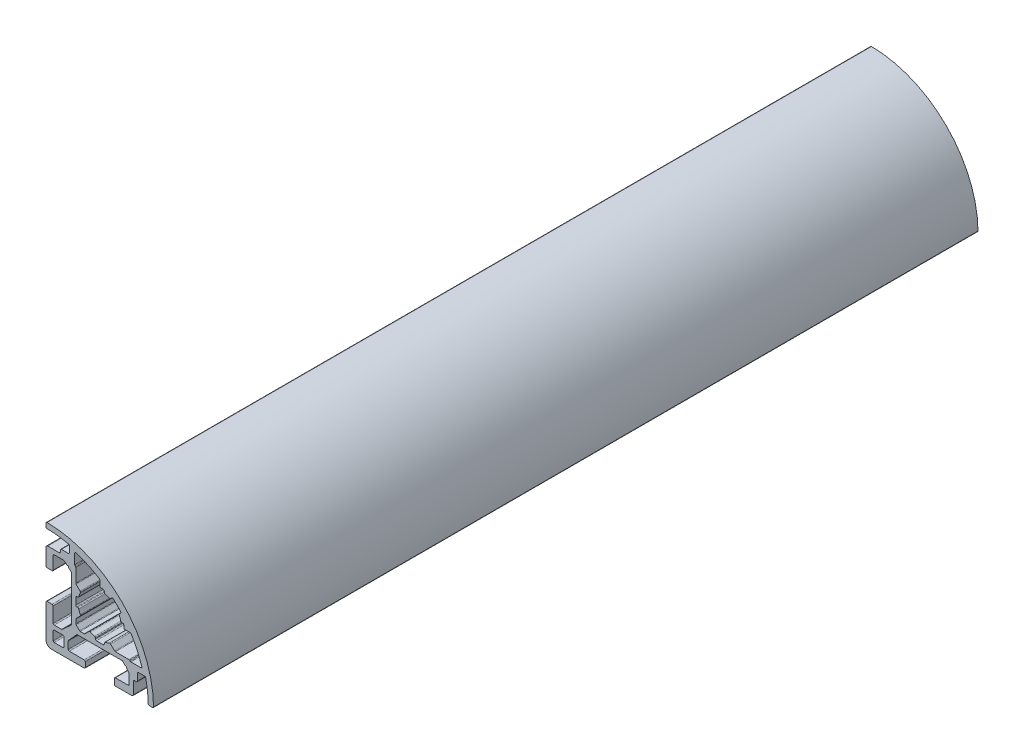
from build123d import *

# Parameters (mm, degrees)
RESSALTO_EXTRUS_O1_DEPTH = 230


with BuildPart() as part:
    # Esboço1 → Ressalto-extrusão1 (new body)
    with BuildSketch(Plane(origin=(0, 0, 0), x_dir=(-1, 0, 0), z_dir=(0, 0, -1))):
        with BuildLine():
            Line((7.988219541, 6.43198304), (8.704487641, 7.072027255))
            Line((8.704487641, 7.072027255), (8.728293149, 7.495764433))
            Line((8.728293149, 7.495764433), (9.151562381, 7.471985214))
            Line((9.151562381, 7.471985214), (9.867827891, 8.112011499))
            ThreePointArc((9.867827891, 8.112011499), (9.965155948, 8.177041744), (10.079961344, 8.199876023))
            Line((10.079961344, 8.199876023), (12.700062747, 8.19983357))
            ThreePointArc((12.700062747, 8.19983357), (12.912193499, 8.111962025), (13.000057886, 7.899828307))
            Line((13.000057886, 7.899828307), (12.999995614, 4.349871329))
            ThreePointArc((12.999995614, 4.349871329), (13.087860246, 4.137737366), (13.299991447, 4.049866067))
            Line((13.299991447, 4.049866067), (14.699990096, 4.049846624))
            ThreePointArc((14.699990096, 4.049846624), (14.912124824, 4.137713117), (14.999994262, 4.349846624))
            Line((14.999994262, 4.349846624), (14.999994262, 8.899908545))
            ThreePointArc((14.999994262, 8.899908545), (14.853547653, 9.253461936), (14.499994262, 9.399908545))
            Line((14.499994262, 9.399908545), (11.299984015, 9.399908545))
            ThreePointArc((11.299984015, 9.399908545), (11.087851981, 9.487776511), (10.999984015, 9.699908545))
            Line((10.999984015, 9.699908545), (10.999984015, 10.199939564))
            ThreePointArc((10.999984015, 10.199939564), (10.91211588, 10.412072007), (10.699983437, 10.499940142))
            Line((10.699983437, 10.499940142), (8.799996289, 10.499940142))
            ThreePointArc((8.799996289, 10.499940142), (8.587864255, 10.587808108), (8.499996289, 10.799940142))
            Line((8.499996289, 10.799940142), (8.499996289, 12.509984621))
            ThreePointArc((8.499996289, 12.509984621), (8.565702422, 12.697351597), (8.734038846, 12.802644177))
            ThreePointArc((8.734038846, 12.802644177), (11.700188414, 13.308311468), (14.703119279, 13.498440079))
            ThreePointArc((14.703119279, 13.498440079), (14.913228295, 13.587399521), (14.999994262, 13.798423803))
            Line((14.999994262, 13.798423803), (14.999994262, 14.698471418))
            ThreePointArc((14.999994262, 14.698471418), (14.911052198, 14.911672141), (14.696963943, 14.998456113))
            ThreePointArc((14.696963943, 14.998456113), (-6.213201777, 6.213195799), (-14.998473404, -14.696965168))
            ThreePointArc((-14.998473404, -14.696965168), (-14.91168949, -14.911053528), (-14.69848871, -14.99999565))
            Line((-14.69848871, -14.99999565), (-13.798441347, -14.99999565))
            ThreePointArc((-13.798441347, -14.99999565), (-13.587416943, -14.913229667), (-13.498457365, -14.70312058))
            ThreePointArc((-13.498457365, -14.70312058), (-13.308326814, -11.700187782), (-12.802657176, -8.734036533))
            ThreePointArc((-12.802657176, -8.734036533), (-12.69756035, -8.565856959), (-12.510499232, -8.499994604))
            Line((-12.510499232, -8.499994604), (-10.800466095, -8.49997976))
            ThreePointArc((-10.800466095, -8.49997976), (-10.588332377, -8.587846805), (-10.500463491, -8.79997976))
            Line((-10.500463491, -8.79997976), (-10.500463491, -10.699963204))
            ThreePointArc((-10.500463491, -10.699963204), (-10.412595525, -10.912095238), (-10.200463491, -10.999963204))
            Line((-10.200463491, -10.999963204), (-9.700412566, -10.999963204))
            ThreePointArc((-9.700412566, -10.999963204), (-9.488279549, -11.087832151), (-9.400412566, -11.299965981))
            Line((-9.400412566, -11.299965981), (-9.400442195, -14.49999102))
            ThreePointArc((-9.400442195, -14.49999102), (-9.253997222, -14.853547404), (-8.900442195, -14.99999565))
            Line((-8.900442195, -14.99999565), (-4.350452588, -14.99999565))
            ThreePointArc((-4.350452588, -14.99999565), (-4.138321045, -14.912128175), (-4.050452588, -14.699997039))
            Line((-4.050452588, -14.699997039), (-4.050446106, -13.299966156))
            ThreePointArc((-4.050446106, -13.299966156), (-4.138313076, -13.087833729), (-4.350444677, -12.999964767))
            Line((-4.350444677, -12.999964767), (-7.900453147, -12.999947852))
            ThreePointArc((-7.900453147, -12.999947852), (-8.112584739, -12.912078899), (-8.200451717, -12.699946488))
            Line((-8.200451717, -12.699946488), (-8.200439807, -10.079879081))
            ThreePointArc((-8.200439807, -10.079879081), (-8.177603146, -9.965074158), (-8.112570881, -9.867747451))
            Line((-8.112570881, -9.867747451), (-7.472516649, -9.151499458))
            Line((-7.472516649, -9.151499458), (-7.496307792, -8.728000464))
            Line((-7.496307792, -8.728000464), (-7.072695416, -8.704202951))
            Line((-7.072695416, -8.704202951), (-6.432641182, -7.987954957))
            ThreePointArc((-6.432641182, -7.987954957), (-6.335313867, -7.922923563), (-6.220508714, -7.900087947))
            Line((-6.220508714, -7.900087947), (6.219693639, -7.900145542))
            ThreePointArc((6.219693639, -7.900145542), (6.334497914, -7.922981945), (6.431824273, -7.988013496))
            Line((6.431824273, -7.988013496), (8.711723784, -10.467916072))
            ThreePointArc((8.711723784, -10.467916072), (8.776761946, -10.565245573), (8.799600801, -10.680055769))
            Line((8.799600801, -10.680055769), (8.799610153, -12.700073336))
            ThreePointArc((8.799610153, -12.700073336), (8.711742976, -12.912205971), (8.499610994, -13.000074725))
            Line((8.499610994, -13.000074725), (4.349601994, -13.000086362))
            ThreePointArc((4.349601994, -13.000086362), (4.137470994, -13.087954134), (4.049602835, -13.300084973))
            Line((4.049602835, -13.300084973), (4.049596354, -14.699994261))
            ThreePointArc((4.049596354, -14.699994261), (4.137463829, -14.912127193), (4.349596354, -14.99999565))
            Line((4.349596354, -14.99999565), (13.499994262, -14.99999565))
            ThreePointArc((13.499994262, -14.99999565), (14.560654434, -14.560655822), (14.999994262, -13.49999565))
            Line((14.999994262, -13.49999565), (14.999994262, -4.350307648))
            ThreePointArc((14.999994262, -4.350307648), (14.912126297, -4.138175613), (14.699994262, -4.050307648))
            Line((14.699994262, -4.050307648), (13.299941692, -4.050307648))
            ThreePointArc((13.299941692, -4.050307648), (13.087809804, -4.138175467), (12.999941692, -4.350307233))
            Line((12.999941692, -4.350307233), (12.999935957, -8.500264456))
            ThreePointArc((12.999935957, -8.500264456), (12.912067599, -8.712396468), (12.699935263, -8.800264041))
            Line((12.699935263, -8.800264041), (10.679833903, -8.800259366))
            ThreePointArc((10.679833903, -8.800259366), (10.565028929, -8.777422961), (10.467702076, -8.712390913))
            Line((10.467702076, -8.712390913), (7.987808147, -6.432485679))
            ThreePointArc((7.987808147, -6.432485679), (7.922994822, -6.335109371), (7.900348133, -6.220348577))
            Line((7.900348133, -6.220348577), (7.900348133, 6.219847563))
            ThreePointArc((7.900348133, 6.219847563), (7.923185205, 6.334654842), (7.988219541, 6.43198304))
        make_face()
        with BuildLine():
            Line((12.699997649, -12.999995366), (10.299997649, -12.999995366))
            ThreePointArc((10.299997649, -12.999995366), (10.087865615, -12.9121274), (9.999997649, -12.699995366))
            Line((9.999997649, -12.699995366), (9.999997649, -10.299995366))
            ThreePointArc((9.999997649, -10.299995366), (10.087865615, -10.087863332), (10.299997649, -9.999995366))
            Line((10.299997649, -9.999995366), (12.699997649, -9.999995366))
            ThreePointArc((12.699997649, -9.999995366), (12.912129683, -10.087863332), (12.999997649, -10.299995366))
            Line((12.999997649, -10.299995366), (12.999997649, -12.699995366))
            ThreePointArc((12.999997649, -12.699995366), (12.912129683, -12.9121274), (12.699997649, -12.999995366))
        make_face(mode=Mode.SUBTRACT)
        with BuildLine():
            Line((-0.949997542, 6.699991608), (-0.300006198, 6.699991608))
            ThreePointArc((-0.300006198, 6.699991608), (-0.087874164, 6.787859574), (-6.198e-06, 6.999991608))
            Line((-6.198e-06, 6.999991608), (-6.198e-06, 8.47764802))
            ThreePointArc((-6.198e-06, 8.47764802), (0.037542168, 8.622972279), (0.140788069, 8.731918614))
            ThreePointArc((0.140788069, 8.731918614), (3.280244614, 10.429262729), (6.61010457, 11.713473425))
            ThreePointArc((6.61010457, 11.713473425), (6.877524397, 11.669091748), (6.999996226, 11.427257614))
            Line((6.999996226, 11.427257614), (6.999996226, 8.679894243))
            ThreePointArc((6.999996226, 8.679894243), (6.977160088, 8.565089218), (6.912128268, 8.467762216))
            Line((6.912128268, 8.467762216), (6.787851146, 8.343485086))
            ThreePointArc((6.787851146, 8.343485086), (6.722819326, 8.246158084), (6.699983188, 8.131353059))
            Line((6.699983188, 8.131353059), (6.699983188, 4.349373523))
            ThreePointArc((6.699983188, 4.349373523), (6.677147048, 4.234568493), (6.612115222, 4.137241489))
            Line((6.612115222, 4.137241489), (5.487142739, 3.012269005))
            ThreePointArc((5.487142739, 3.012269005), (5.403317864, 2.849223708), (5.430017697, 2.667847035))
            ThreePointArc((5.430017697, 2.667847035), (5.679815237, 2.083794343), (5.866996881, 1.47676931))
            ThreePointArc((5.866996881, 1.47676931), (5.973488711, 1.313387662), (6.157922346, 1.249997541))
            Line((6.157922346, 1.249997541), (6.399983188, 1.249997541))
            ThreePointArc((6.399983188, 1.249997541), (6.612115222, 1.162129575), (6.699983188, 0.949997541))
            Line((6.699983188, 0.949997541), (6.699983188, -0.949997542))
            ThreePointArc((6.699983188, -0.949997542), (6.612115222, -1.162129576), (6.399983188, -1.249997542))
            Line((6.399983188, -1.249997542), (6.157922346, -1.249997542))
            ThreePointArc((6.157922346, -1.249997542), (5.973488711, -1.313387663), (5.866996881, -1.476769311))
            ThreePointArc((5.866996881, -1.476769311), (5.679815237, -2.083794344), (5.430017697, -2.667847036))
            ThreePointArc((5.430017697, -2.667847036), (5.403317864, -2.849223709), (5.487142739, -3.012269006))
            Line((5.487142739, -3.012269006), (6.612115222, -4.13724149))
            ThreePointArc((6.612115222, -4.13724149), (6.677147048, -4.234568494), (6.699983188, -4.349373524))
            Line((6.699983188, -4.349373524), (6.699983188, -5.439573887))
            ThreePointArc((6.699983188, -5.439573887), (6.677147048, -5.554378917), (6.612115222, -5.651705921))
            Line((6.612115222, -5.651705921), (5.651680826, -6.612140317))
            ThreePointArc((5.651680826, -6.612140317), (5.554353822, -6.677172143), (5.439548792, -6.700008283))
            Line((5.439548792, -6.700008283), (4.349398617, -6.700008283))
            ThreePointArc((4.349398617, -6.700008283), (4.234593588, -6.677172143), (4.137266583, -6.612140317))
            Line((4.137266583, -6.612140317), (3.012269005, -5.48714274))
            ThreePointArc((3.012269005, -5.48714274), (2.849223708, -5.403317864), (2.667847035, -5.430017698))
            ThreePointArc((2.667847035, -5.430017698), (2.083794343, -5.679815238), (1.47676931, -5.866996882))
            ThreePointArc((1.47676931, -5.866996882), (1.313387662, -5.973488713), (1.24999754, -6.157922347))
            Line((1.24999754, -6.157922347), (1.24999754, -6.400008283))
            ThreePointArc((1.24999754, -6.400008283), (1.162129575, -6.612140317), (0.94999754, -6.700008283))
            Line((0.94999754, -6.700008283), (-0.949997542, -6.700008283))
            ThreePointArc((-0.949997542, -6.700008283), (-1.162129576, -6.612140317), (-1.249997542, -6.400008283))
            Line((-1.249997542, -6.400008283), (-1.249997542, -6.157922347))
            ThreePointArc((-1.249997542, -6.157922347), (-1.313387663, -5.973488713), (-1.476769311, -5.866996882))
            ThreePointArc((-1.476769311, -5.866996882), (-2.083794344, -5.679815238), (-2.667847036, -5.430017698))
            ThreePointArc((-2.667847036, -5.430017698), (-2.849223709, -5.403317865), (-3.012269006, -5.48714274))
            Line((-3.012269006, -5.48714274), (-4.137266583, -6.612140317))
            ThreePointArc((-4.137266583, -6.612140317), (-4.234593588, -6.677172143), (-4.349398618, -6.700008283))
            Line((-4.349398618, -6.700008283), (-8.131377093, -6.700008283))
            ThreePointArc((-8.131377093, -6.700008283), (-8.246182127, -6.722844425), (-8.343509135, -6.787876256))
            Line((-8.343509135, -6.787876256), (-8.467778577, -6.912145707))
            ThreePointArc((-8.467778577, -6.912145707), (-8.565105584, -6.977177538), (-8.679910619, -7.00001368))
            Line((-8.679910619, -7.00001368), (-11.427275069, -7.00001368))
            ThreePointArc((-11.427275069, -7.00001368), (-11.669109203, -6.877541852), (-11.713490879, -6.610122025))
            ThreePointArc((-11.713490879, -6.610122025), (-10.429280184, -3.280262068), (-8.731936068, -0.140805524))
            ThreePointArc((-8.731936068, -0.140805524), (-8.622989733, -0.037559623), (-8.477665474, -1.1256e-05))
            Line((-8.477665474, -1.1256e-05), (-7.000004228, -1.1256e-05))
            ThreePointArc((-7.000004228, -1.1256e-05), (-6.787872194, 0.08785671), (-6.700004228, 0.299988744))
            Line((-6.700004228, 0.299988744), (-6.700004228, 0.94999754))
            ThreePointArc((-6.700004228, 0.94999754), (-6.612136263, 1.162129574), (-6.400004228, 1.24999754))
            Line((-6.400004228, 1.24999754), (-6.157922347, 1.24999754))
            ThreePointArc((-6.157922347, 1.24999754), (-5.973488713, 1.313387661), (-5.866996882, 1.476769309))
            ThreePointArc((-5.866996882, 1.476769309), (-5.679815238, 2.083794343), (-5.430017698, 2.667847035))
            ThreePointArc((-5.430017698, 2.667847035), (-5.403317865, 2.849223708), (-5.48714274, 3.012269005))
            Line((-5.48714274, 3.012269005), (-5.797444779, 3.322571045))
            ThreePointArc((-5.797444779, 3.322571045), (-5.885209902, 3.526848471), (-5.808258232, 3.735439996))
            ThreePointArc((-5.808258232, 3.735439996), (-4.798993375, 4.798993588), (-3.735438882, 5.808257496))
            ThreePointArc((-3.735438882, 5.808257496), (-3.526847423, 5.885208983), (-3.322570131, 5.797443864))
            Line((-3.322570131, 5.797443864), (-3.012269006, 5.487142739))
            ThreePointArc((-3.012269006, 5.487142739), (-2.849223709, 5.403317864), (-2.667847036, 5.430017697))
            ThreePointArc((-2.667847036, 5.430017697), (-2.083794344, 5.679815237), (-1.476769311, 5.866996881))
            ThreePointArc((-1.476769311, 5.866996881), (-1.313387663, 5.973488711), (-1.249997542, 6.157922346))
            Line((-1.249997542, 6.157922346), (-1.249997542, 6.399991608))
            ThreePointArc((-1.249997542, 6.399991608), (-1.162129576, 6.612123643), (-0.949997542, 6.699991608))
        make_face(mode=Mode.SUBTRACT)
    extrude(amount=-RESSALTO_EXTRUS_O1_DEPTH)


solid = part.part
